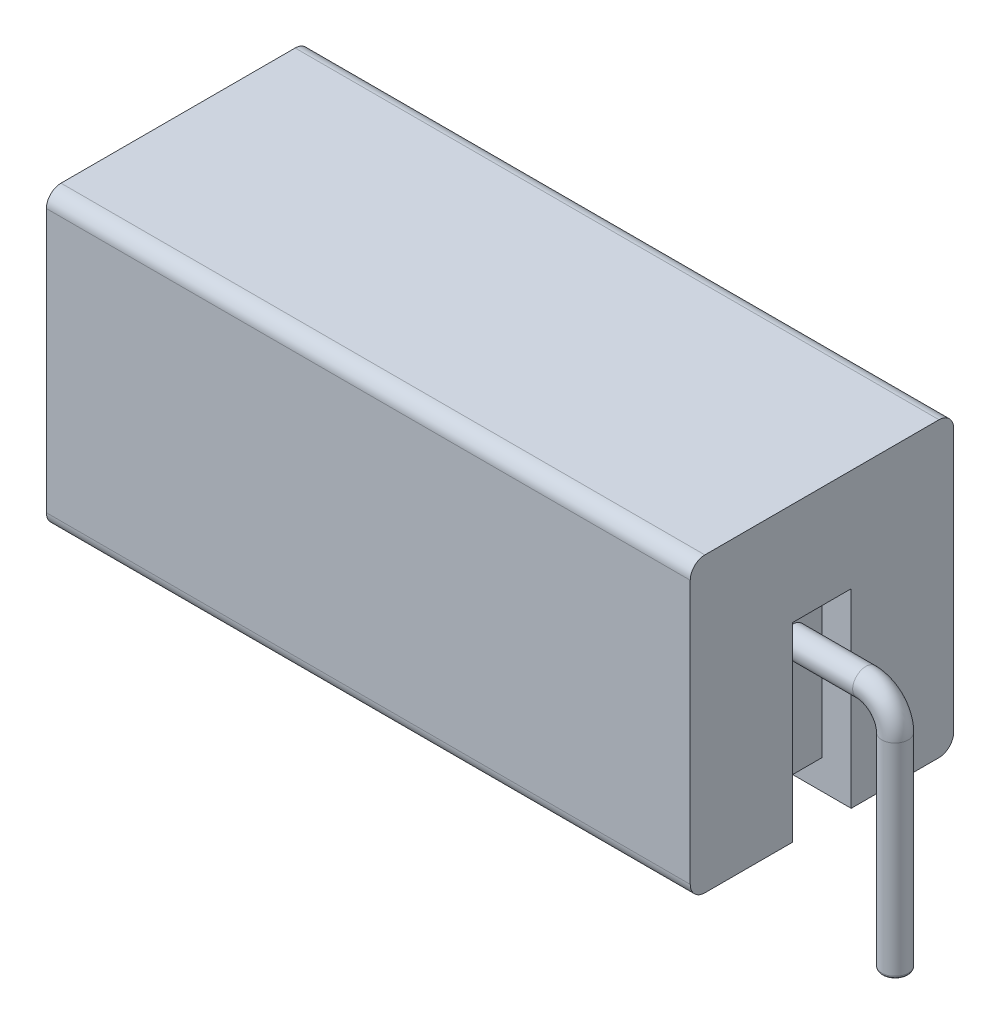
from build123d import *

# Parameters (mm, degrees)
SKETCH1_W           = 22
SKETCH1_H           = 10
BOSS_EXTRUDE1_DEPTH = 9
FILLET2_R           = 0.5
CUT_EXTRUDE4_DEPTH  = 1
SKETCH8_W           = 2
SKETCH8_H           = 6.5
CUT_EXTRUDE5_DEPTH  = 1
CUT_EXTRUDE6_DEPTH  = 1
SKETCH13_R          = 0.45
FILLET3_R           = 0.1


with BuildPart() as part:
    # Sketch1 → Boss-Extrude1 (new body)
    with BuildSketch(Plane.XY):
        with Locations((11, -5)):
            Rectangle(SKETCH1_W, SKETCH1_H)
    extrude(amount=BOSS_EXTRUDE1_DEPTH)

    # Fillet2
    fillet2_edges = [part.edges().sort_by_distance(p)[0] for p in [
        (11, 0, 9),
        (11, 0, 0),
        (11, -10, 0),
        (11, -10, 9),
    ]]
    fillet(fillet2_edges, radius=FILLET2_R)

    # 3DSketch1 → Cut-Extrude4 (cut)
    with BuildSketch(Plane(origin=(22, -10, 5.5), x_dir=(0, 0.9557790087219501, -0.29408584883752314), z_dir=(1, 0, 0))):
        Polygon((0, 0), (6.212563557, 1.911558017), (6.800735254, 0), (0.588171698, -1.911558017), align=None)
    extrude(amount=-CUT_EXTRUDE4_DEPTH, mode=Mode.SUBTRACT)

    # Sketch8 → Cut-Extrude5 (cut)
    with BuildSketch(Plane.ZY):
        with Locations((4.5, -6.75)):
            Rectangle(SKETCH8_W, SKETCH8_H)
    extrude(amount=-CUT_EXTRUDE5_DEPTH, mode=Mode.SUBTRACT)

    # Sketch6 → Cut-Extrude6 (cut)
    with BuildSketch(Plane.XZ.offset(10)):
        Polygon((1, 5.5), (1, 3.5), (3, 3.5), (3, 1), (19, 1), (19, 3.5), (21, 3.5), (21, 5.5), (19, 5.5), (19, 8), (3, 8), (3, 5.5), align=None)
    extrude(amount=-CUT_EXTRUDE6_DEPTH, mode=Mode.SUBTRACT)

    # Sweep1: sweep along a curve in space
    with BuildLine() as sweep1_path:
        Line((21, -5, 4.5), (23.5, -5, 4.5))
        ThreePointArc((24.5, -6, 4.5), (24.207106781, -5.292893219, 4.5), (23.5, -5, 4.5))
        Line((24.5, -6, 4.5), (24.5, -13, 4.5))
    # Sketch13 → Sweep1 (sweep)
    with BuildSketch(Plane(origin=(21, 0, 0), x_dir=(0, 0, -1), z_dir=(1, 0, 0))):
        with Locations((-4.5, -5)):
            Circle(SKETCH13_R)
    sweep1 = sweep(path=sweep1_path.line)

    # Mirror1: Sweep1 across plane
    add(sweep1.mirror(Plane(origin=(11, 0, 0), x_dir=(0, 0, 1), z_dir=(1, 0, 0))))

    # Fillet3
    fillet3_edges = [part.edges().sort_by_distance(p)[0] for p in [
        (24.5, -13, 4.95),
        (-2.5, -13, 4.95),
    ]]
    fillet(fillet3_edges, radius=FILLET3_R)


solid = part.part
